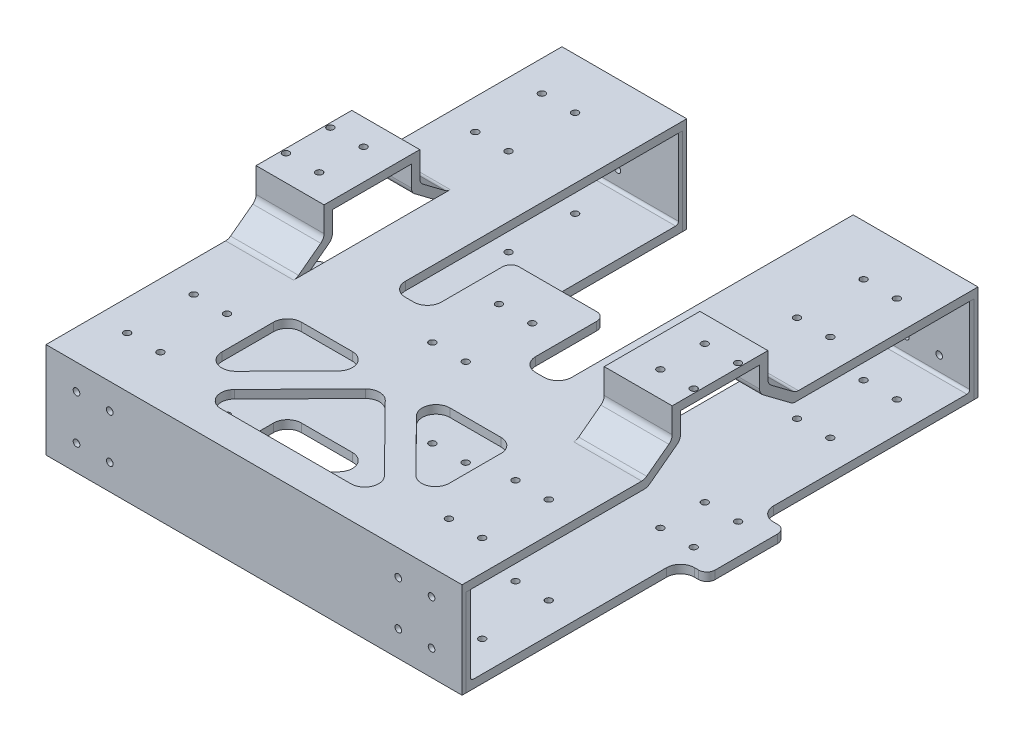
from build123d import *

# Parameters (mm, degrees)
BOSS_EXTRUDE1_DEPTH            = 84.5
BOSS_EXTRUDE2_DEPTH            = 34
BOSS_EXTRUDE4_DEPTH            = 50.5
CUT_EXTRUDE1_DEPTH             = 53.5
SKETCH16_W                     = 9.5
SKETCH16_H                     = 28.5
CUT_EXTRUDE2_DEPTH             = 3
SKETCH13_W                     = 1.2
SKETCH13_H                     = 52.5
M2_CLEARANCE_HOLE4_AT_2_COUNT  = 2
M2_CLEARANCE_HOLE4_AT_2_PITCH  = 12
M2_CLEARANCE_HOLE4_AT_3_COUNT  = 2
M2_CLEARANCE_HOLE4_AT_3_PITCH  = 26.83281573
M2_CLEARANCE_HOLE4_AT_4_COUNT  = 2
M2_CLEARANCE_HOLE4_AT_4_PITCH  = 24
M2_CLEARANCE_HOLE4_AT_5_COUNT  = 2
M2_CLEARANCE_HOLE4_AT_5_PITCH  = 70.127116724
M2_CLEARANCE_HOLE4_AT_6_COUNT  = 2
M2_CLEARANCE_HOLE4_AT_6_PITCH  = 85.497441482
M2_CLEARANCE_HOLE4_AT_7_COUNT  = 2
M2_CLEARANCE_HOLE4_AT_7_PITCH  = 149.980832109
M2_CLEARANCE_HOLE4_AT_8_COUNT  = 2
M2_CLEARANCE_HOLE4_AT_8_PITCH  = 149.5
M2_CLEARANCE_HOLE4_AT_9_COUNT  = 2
M2_CLEARANCE_HOLE4_AT_9_PITCH  = 125.5
M2_CLEARANCE_HOLE4_AT_10_COUNT = 2
M2_CLEARANCE_HOLE4_AT_10_PITCH = 126.072399834
M2_CLEARANCE_HOLE4_AT_11_COUNT = 2
M2_CLEARANCE_HOLE4_AT_11_PITCH = 69.465319451
M2_CLEARANCE_HOLE4_AT_12_COUNT = 2
M2_CLEARANCE_HOLE4_AT_12_PITCH = 88.881582923
M2_CLEARANCE_HOLE4_AT_13_COUNT = 2
M2_CLEARANCE_HOLE4_AT_13_PITCH = 67.422640856
M2_CLEARANCE_HOLE4_AT_14_COUNT = 2
M2_CLEARANCE_HOLE4_AT_14_PITCH = 83.293532162
SKETCH18_W                     = 1.2
SKETCH18_H                     = 186
M2_CLEARANCE_HOLE5_AT_2_COUNT  = 2
M2_CLEARANCE_HOLE5_AT_2_PITCH  = 16
M2_CLEARANCE_HOLE5_AT_3_COUNT  = 2
M2_CLEARANCE_HOLE5_AT_3_PITCH  = 20
M2_CLEARANCE_HOLE5_AT_4_COUNT  = 2
M2_CLEARANCE_HOLE5_AT_4_PITCH  = 12
CUT_EXTRUDE3_DEPTH             = 53.5
FILLET1_R                      = 5
FILLET2_R                      = 3
FILLET3_R                      = 1
FILLET5_R                      = 3
FILLET7_R                      = 5


with BuildPart() as part:
    # Sketch4 → Boss-Extrude1 (new body)
    with BuildSketch(Plane(origin=(0, 0, 0), x_dir=(0, 0, -1), z_dir=(1, 0, 0))):
        Polygon((-91.5, 28.5), (-90, 28.5), (-90, 0), (90, 0), (90, 28.5), (91.5, 28.5), (91.5, -3), (-91.5, -3), align=None)
    extrude(amount=BOSS_EXTRUDE1_DEPTH)


with BuildPart() as body_2:
    # Sketch14 → Boss-Extrude2 (new body)
    with BuildSketch(Plane(origin=(50.499999928, 0, 0), x_dir=(0, 0, -1), z_dir=(1, 0, 0))):
        Polygon((-93, -3), (-91.5, -3), (-91.5, 28.5), (-26.25, 28.5), (-22.25, 31.5), (-27.25, 31.5), (-93, 31.5), align=None)
        Polygon((-27.25, 31.5), (-22.25, 31.5), (-14.25, 37.5), (-14.25, 46.5), (14.25, 46.5), (14.25, 37.5), (22.25, 31.5), (27.25, 31.5), (17.25, 39), (17.25, 49.5), (-17.25, 49.5), (-17.25, 39), align=None)
        Polygon((22.25, 31.5), (26.25, 28.5), (91.5, 28.5), (91.5, -3), (93, -3), (93, 31.5), (27.25, 31.5), align=None)
    extrude(amount=BOSS_EXTRUDE2_DEPTH)

    # Sketch14_6 → Boss-Extrude4 (add)
    with BuildSketch(Plane(origin=(50.499999928, 0, 0), x_dir=(0, 0, -1), z_dir=(1, 0, 0))):
        Polygon((-93, -3), (-91.5, -3), (-91.5, 28.5), (91.5, 28.5), (91.5, -3), (93, -3), (93, 31.5), (-93, 31.5), align=None)
    extrude(amount=-BOSS_EXTRUDE4_DEPTH)


with BuildPart() as cut_extrude1_tool:
    # Sketch7 → Cut-Extrude1 (new body, through all)
    with BuildSketch(Plane.XZ.offset(3)):
        Polygon((84.5, -14.25), (75, -14.25), (75, -93), (84.499999928, -93), align=None)
        Polygon((84.5, 14.25), (75, 14.25), (75, 93), (84.499999928, 93), align=None)
        Polygon((0, -93), (30, -93), (30, 13.447808823), (17, 13.447808823), (17, -16.552191177), (0, -16.552191177), align=None)
    extrude(amount=-CUT_EXTRUDE1_DEPTH)


with BuildPart() as part_1:
    add(part.part)

    # Cut-Extrude1: cut by cut_extrude1_tool
    add(cut_extrude1_tool.part, mode=Mode.SUBTRACT)


with BuildPart() as body_2_1:
    add(body_2.part)

    # Cut-Extrude1: cut by cut_extrude1_tool
    add(cut_extrude1_tool.part, mode=Mode.SUBTRACT)

    # Sketch16 → Cut-Extrude2 (cut)
    with BuildSketch(Plane(origin=(0, 49.5, 0), x_dir=(1, 0, 0), z_dir=(0, 1, 0))):
        with Locations((79.75, 0)):
            Rectangle(SKETCH16_W, SKETCH16_H)
    extrude(amount=-CUT_EXTRUDE2_DEPTH, mode=Mode.SUBTRACT)


with BuildPart() as m2_clearance_hole4_tool:
    # Sketch13 → M2 Clearance Hole4 (revolve)
    with BuildSketch(Plane(origin=(52, -3, 74.75), x_dir=(0, 0, -1), z_dir=(1, 0, 0))):
        with Locations((0.6, 26.25)):
            Rectangle(SKETCH13_W, SKETCH13_H)
    m2_clearance_hole4 = revolve(axis=Axis((52, -9.35, 74.75), (0, 1, 0)))


with BuildPart() as part_2:
    add(part_1.part)

    # M2 Clearance Hole4: cut by m2_clearance_hole4_tool
    add(m2_clearance_hole4_tool.part, mode=Mode.SUBTRACT)


with BuildPart() as body_2_2:
    add(body_2_1.part)

    # M2 Clearance Hole4: cut by m2_clearance_hole4_tool
    add(m2_clearance_hole4_tool.part, mode=Mode.SUBTRACT)


with BuildPart() as m2_clearance_hole4_at_2_tool:
    # M2 Clearance Hole4 at 2: M2 Clearance Hole4 ×2
    with Locations(*[(i * M2_CLEARANCE_HOLE4_AT_2_PITCH, 0, 0) for i in range(1, M2_CLEARANCE_HOLE4_AT_2_COUNT)]):
        add(m2_clearance_hole4)


with BuildPart() as part_3:
    add(part_2.part)

    # M2 Clearance Hole4 at 2: cut by m2_clearance_hole4_at_2_tool
    add(m2_clearance_hole4_at_2_tool.part, mode=Mode.SUBTRACT)


with BuildPart() as body_2_3:
    add(body_2_2.part)

    # M2 Clearance Hole4 at 2: cut by m2_clearance_hole4_at_2_tool
    add(m2_clearance_hole4_at_2_tool.part, mode=Mode.SUBTRACT)


with BuildPart() as m2_clearance_hole4_at_3_tool:
    # M2 Clearance Hole4 at 3: M2 Clearance Hole4 ×2
    with Locations(*[Vector(0.447213595, 0, -0.894427191) * (i * M2_CLEARANCE_HOLE4_AT_3_PITCH) for i in range(1, M2_CLEARANCE_HOLE4_AT_3_COUNT)]):
        add(m2_clearance_hole4)


with BuildPart() as part_4:
    add(part_3.part)

    # M2 Clearance Hole4 at 3: cut by m2_clearance_hole4_at_3_tool
    add(m2_clearance_hole4_at_3_tool.part, mode=Mode.SUBTRACT)


with BuildPart() as body_2_4:
    add(body_2_3.part)

    # M2 Clearance Hole4 at 3: cut by m2_clearance_hole4_at_3_tool
    add(m2_clearance_hole4_at_3_tool.part, mode=Mode.SUBTRACT)


with BuildPart() as m2_clearance_hole4_at_4_tool:
    # M2 Clearance Hole4 at 4: M2 Clearance Hole4 ×2
    with Locations(*[(0, 0, -i * M2_CLEARANCE_HOLE4_AT_4_PITCH) for i in range(1, M2_CLEARANCE_HOLE4_AT_4_COUNT)]):
        add(m2_clearance_hole4)


with BuildPart() as part_5:
    add(part_4.part)

    # M2 Clearance Hole4 at 4: cut by m2_clearance_hole4_at_4_tool
    add(m2_clearance_hole4_at_4_tool.part, mode=Mode.SUBTRACT)


with BuildPart() as body_2_5:
    add(body_2_4.part)

    # M2 Clearance Hole4 at 4: cut by m2_clearance_hole4_at_4_tool
    add(m2_clearance_hole4_at_4_tool.part, mode=Mode.SUBTRACT)


with BuildPart() as m2_clearance_hole4_at_5_tool:
    # M2 Clearance Hole4 at 5: M2 Clearance Hole4 ×2
    with Locations(*[Vector(0.306586111, 0, -0.951842926) * (i * M2_CLEARANCE_HOLE4_AT_5_PITCH) for i in range(1, M2_CLEARANCE_HOLE4_AT_5_COUNT)]):
        add(m2_clearance_hole4)


with BuildPart() as part_6:
    add(part_5.part)

    # M2 Clearance Hole4 at 5: cut by m2_clearance_hole4_at_5_tool
    add(m2_clearance_hole4_at_5_tool.part, mode=Mode.SUBTRACT)


with BuildPart() as body_2_6:
    add(body_2_5.part)

    # M2 Clearance Hole4 at 5: cut by m2_clearance_hole4_at_5_tool
    add(m2_clearance_hole4_at_5_tool.part, mode=Mode.SUBTRACT)


with BuildPart() as m2_clearance_hole4_at_6_tool:
    # M2 Clearance Hole4 at 6: M2 Clearance Hole4 ×2
    with Locations(*[Vector(0.251469513, 0, -0.96786522) * (i * M2_CLEARANCE_HOLE4_AT_6_PITCH) for i in range(1, M2_CLEARANCE_HOLE4_AT_6_COUNT)]):
        add(m2_clearance_hole4)


with BuildPart() as part_7:
    add(part_6.part)

    # M2 Clearance Hole4 at 6: cut by m2_clearance_hole4_at_6_tool
    add(m2_clearance_hole4_at_6_tool.part, mode=Mode.SUBTRACT)


with BuildPart() as body_2_7:
    add(body_2_6.part)

    # M2 Clearance Hole4 at 6: cut by m2_clearance_hole4_at_6_tool
    add(m2_clearance_hole4_at_6_tool.part, mode=Mode.SUBTRACT)


with BuildPart() as m2_clearance_hole4_at_7_tool:
    # M2 Clearance Hole4 at 7: M2 Clearance Hole4 ×2
    with Locations(*[Vector(0.080010224, 0, -0.996794043) * (i * M2_CLEARANCE_HOLE4_AT_7_PITCH) for i in range(1, M2_CLEARANCE_HOLE4_AT_7_COUNT)]):
        add(m2_clearance_hole4)


with BuildPart() as part_8:
    add(part_7.part)

    # M2 Clearance Hole4 at 7: cut by m2_clearance_hole4_at_7_tool
    add(m2_clearance_hole4_at_7_tool.part, mode=Mode.SUBTRACT)


with BuildPart() as body_2_8:
    add(body_2_7.part)

    # M2 Clearance Hole4 at 7: cut by m2_clearance_hole4_at_7_tool
    add(m2_clearance_hole4_at_7_tool.part, mode=Mode.SUBTRACT)


with BuildPart() as m2_clearance_hole4_at_8_tool:
    # M2 Clearance Hole4 at 8: M2 Clearance Hole4 ×2
    with Locations(*[(0, 0, -i * M2_CLEARANCE_HOLE4_AT_8_PITCH) for i in range(1, M2_CLEARANCE_HOLE4_AT_8_COUNT)]):
        add(m2_clearance_hole4)


with BuildPart() as part_9:
    add(part_8.part)

    # M2 Clearance Hole4 at 8: cut by m2_clearance_hole4_at_8_tool
    add(m2_clearance_hole4_at_8_tool.part, mode=Mode.SUBTRACT)


with BuildPart() as body_2_9:
    add(body_2_8.part)

    # M2 Clearance Hole4 at 8: cut by m2_clearance_hole4_at_8_tool
    add(m2_clearance_hole4_at_8_tool.part, mode=Mode.SUBTRACT)


with BuildPart() as m2_clearance_hole4_at_9_tool:
    # M2 Clearance Hole4 at 9: M2 Clearance Hole4 ×2
    with Locations(*[(0, 0, -i * M2_CLEARANCE_HOLE4_AT_9_PITCH) for i in range(1, M2_CLEARANCE_HOLE4_AT_9_COUNT)]):
        add(m2_clearance_hole4)


with BuildPart() as part_10:
    add(part_9.part)

    # M2 Clearance Hole4 at 9: cut by m2_clearance_hole4_at_9_tool
    add(m2_clearance_hole4_at_9_tool.part, mode=Mode.SUBTRACT)


with BuildPart() as body_2_10:
    add(body_2_9.part)

    # M2 Clearance Hole4 at 9: cut by m2_clearance_hole4_at_9_tool
    add(m2_clearance_hole4_at_9_tool.part, mode=Mode.SUBTRACT)


with BuildPart() as m2_clearance_hole4_at_10_tool:
    # M2 Clearance Hole4 at 10: M2 Clearance Hole4 ×2
    with Locations(*[Vector(0.095183403, 0, -0.995459753) * (i * M2_CLEARANCE_HOLE4_AT_10_PITCH) for i in range(1, M2_CLEARANCE_HOLE4_AT_10_COUNT)]):
        add(m2_clearance_hole4)


with BuildPart() as part_11:
    add(part_10.part)

    # M2 Clearance Hole4 at 10: cut by m2_clearance_hole4_at_10_tool
    add(m2_clearance_hole4_at_10_tool.part, mode=Mode.SUBTRACT)


with BuildPart() as body_2_11:
    add(body_2_10.part)

    # M2 Clearance Hole4 at 10: cut by m2_clearance_hole4_at_10_tool
    add(m2_clearance_hole4_at_10_tool.part, mode=Mode.SUBTRACT)


with BuildPart() as m2_clearance_hole4_at_11_tool:
    # M2 Clearance Hole4 at 11: M2 Clearance Hole4 ×2
    with Locations(*[Vector(-0.662200942, 0, -0.749326305) * (i * M2_CLEARANCE_HOLE4_AT_11_PITCH) for i in range(1, M2_CLEARANCE_HOLE4_AT_11_COUNT)]):
        add(m2_clearance_hole4)


with BuildPart() as part_12:
    add(part_11.part)

    # M2 Clearance Hole4 at 11: cut by m2_clearance_hole4_at_11_tool
    add(m2_clearance_hole4_at_11_tool.part, mode=Mode.SUBTRACT)


with BuildPart() as body_2_12:
    add(body_2_11.part)

    # M2 Clearance Hole4 at 11: cut by m2_clearance_hole4_at_11_tool
    add(m2_clearance_hole4_at_11_tool.part, mode=Mode.SUBTRACT)


with BuildPart() as m2_clearance_hole4_at_12_tool:
    # M2 Clearance Hole4 at 12: M2 Clearance Hole4 ×2
    with Locations(*[Vector(-0.517542538, 0, -0.855657479) * (i * M2_CLEARANCE_HOLE4_AT_12_PITCH) for i in range(1, M2_CLEARANCE_HOLE4_AT_12_COUNT)]):
        add(m2_clearance_hole4)


with BuildPart() as part_13:
    add(part_12.part)

    # M2 Clearance Hole4 at 12: cut by m2_clearance_hole4_at_12_tool
    add(m2_clearance_hole4_at_12_tool.part, mode=Mode.SUBTRACT)


with BuildPart() as body_2_13:
    add(body_2_12.part)

    # M2 Clearance Hole4 at 12: cut by m2_clearance_hole4_at_12_tool
    add(m2_clearance_hole4_at_12_tool.part, mode=Mode.SUBTRACT)


with BuildPart() as m2_clearance_hole4_at_13_tool:
    # M2 Clearance Hole4 at 13: M2 Clearance Hole4 ×2
    with Locations(*[Vector(0.140902223, 0, -0.990023517) * (i * M2_CLEARANCE_HOLE4_AT_13_PITCH) for i in range(1, M2_CLEARANCE_HOLE4_AT_13_COUNT)]):
        add(m2_clearance_hole4)


with BuildPart() as part_14:
    add(part_13.part)

    # M2 Clearance Hole4 at 13: cut by m2_clearance_hole4_at_13_tool
    add(m2_clearance_hole4_at_13_tool.part, mode=Mode.SUBTRACT)


with BuildPart() as body_2_14:
    add(body_2_13.part)

    # M2 Clearance Hole4 at 13: cut by m2_clearance_hole4_at_13_tool
    add(m2_clearance_hole4_at_13_tool.part, mode=Mode.SUBTRACT)


with BuildPart() as m2_clearance_hole4_at_14_tool:
    # M2 Clearance Hole4 at 14: M2 Clearance Hole4 ×2
    with Locations(*[Vector(0.114054474, 0, -0.993474497) * (i * M2_CLEARANCE_HOLE4_AT_14_PITCH) for i in range(1, M2_CLEARANCE_HOLE4_AT_14_COUNT)]):
        add(m2_clearance_hole4)


with BuildPart() as part_15:
    add(part_14.part)

    # M2 Clearance Hole4 at 14: cut by m2_clearance_hole4_at_14_tool
    add(m2_clearance_hole4_at_14_tool.part, mode=Mode.SUBTRACT)


with BuildPart() as body_2_15:
    add(body_2_14.part)

    # M2 Clearance Hole4 at 14: cut by m2_clearance_hole4_at_14_tool
    add(m2_clearance_hole4_at_14_tool.part, mode=Mode.SUBTRACT)


with BuildPart() as m2_clearance_hole5_tool:
    # Sketch18 → M2 Clearance Hole5 (revolve)
    with BuildSketch(Plane(origin=(52, 22.25, 93), x_dir=(0, -1, 0), z_dir=(1, 0, 0))):
        with Locations((0.6, 93)):
            Rectangle(SKETCH18_W, SKETCH18_H)
    m2_clearance_hole5 = revolve(axis=Axis((52, 22.25, 99.35), (0, 0, -1)))


with BuildPart() as part_16:
    add(part_15.part)

    # M2 Clearance Hole5: cut by m2_clearance_hole5_tool
    add(m2_clearance_hole5_tool.part, mode=Mode.SUBTRACT)


with BuildPart() as body_2_16:
    add(body_2_15.part)

    # M2 Clearance Hole5: cut by m2_clearance_hole5_tool
    add(m2_clearance_hole5_tool.part, mode=Mode.SUBTRACT)


with BuildPart() as m2_clearance_hole5_at_2_tool:
    # M2 Clearance Hole5 at 2: M2 Clearance Hole5 ×2
    with Locations(*[(0, -i * M2_CLEARANCE_HOLE5_AT_2_PITCH, 0) for i in range(1, M2_CLEARANCE_HOLE5_AT_2_COUNT)]):
        add(m2_clearance_hole5)


with BuildPart() as part_17:
    add(part_16.part)

    # M2 Clearance Hole5 at 2: cut by m2_clearance_hole5_at_2_tool
    add(m2_clearance_hole5_at_2_tool.part, mode=Mode.SUBTRACT)


with BuildPart() as body_2_17:
    add(body_2_16.part)

    # M2 Clearance Hole5 at 2: cut by m2_clearance_hole5_at_2_tool
    add(m2_clearance_hole5_at_2_tool.part, mode=Mode.SUBTRACT)


with BuildPart() as m2_clearance_hole5_at_3_tool:
    # M2 Clearance Hole5 at 3: M2 Clearance Hole5 ×2
    with Locations(*[Vector(0.6, -0.8, 0) * (i * M2_CLEARANCE_HOLE5_AT_3_PITCH) for i in range(1, M2_CLEARANCE_HOLE5_AT_3_COUNT)]):
        add(m2_clearance_hole5)


with BuildPart() as part_18:
    add(part_17.part)

    # M2 Clearance Hole5 at 3: cut by m2_clearance_hole5_at_3_tool
    add(m2_clearance_hole5_at_3_tool.part, mode=Mode.SUBTRACT)


with BuildPart() as body_2_18:
    add(body_2_17.part)

    # M2 Clearance Hole5 at 3: cut by m2_clearance_hole5_at_3_tool
    add(m2_clearance_hole5_at_3_tool.part, mode=Mode.SUBTRACT)


with BuildPart() as m2_clearance_hole5_at_4_tool:
    # M2 Clearance Hole5 at 4: M2 Clearance Hole5 ×2
    with Locations(*[(i * M2_CLEARANCE_HOLE5_AT_4_PITCH, 0, 0) for i in range(1, M2_CLEARANCE_HOLE5_AT_4_COUNT)]):
        add(m2_clearance_hole5)


with BuildPart() as part_19:
    add(part_18.part)

    # M2 Clearance Hole5 at 4: cut by m2_clearance_hole5_at_4_tool
    add(m2_clearance_hole5_at_4_tool.part, mode=Mode.SUBTRACT)

    # Mirror1: part across plane


with BuildPart() as body_2_19:
    add(body_2_18.part)

    # M2 Clearance Hole5 at 4: cut by m2_clearance_hole5_at_4_tool
    add(m2_clearance_hole5_at_4_tool.part, mode=Mode.SUBTRACT)

    # Mirror1 2: body 2 across plane


with BuildPart() as part_20:
    add(part_19.part)
    add(part_19.part.mirror(Plane(origin=(0, 0, 0), x_dir=(0, 0, 1), z_dir=(1, 0, 0))))


with BuildPart() as body_2_20:
    add(body_2_19.part)
    add(body_2_19.part.mirror(Plane(origin=(0, 0, 0), x_dir=(0, 0, 1), z_dir=(1, 0, 0))))


with BuildPart() as cut_extrude3_tool:
    # Sketch19 → Cut-Extrude3 (new body, through all)
    with BuildSketch(Plane.XZ.offset(3)):
        Polygon((41, 75.804924873), (5.619392711, 39.947808823), (41, 39.947808823), align=None)
        Polygon((35.380607289, 81.5), (-35.380607289, 81.5), (0, 45.64288395), align=None)
        Polygon((-5.619392711, 39.947808823), (-41, 75.804924873), (-41, 39.947808823), align=None)
    extrude(amount=-CUT_EXTRUDE3_DEPTH)


with BuildPart() as part_21:
    add(part_20.part)

    # Cut-Extrude3: cut by cut_extrude3_tool
    add(cut_extrude3_tool.part, mode=Mode.SUBTRACT)

    # Fillet1
    fillet1_edges = [part_21.edges().sort_by_distance(p)[0] for p in [
        (-17, -1.5, 13.447808823),
        (-30, -1.5, 13.447808823),
        (-75, -1.5, 14.25),
        (-75, -1.5, -14.25),
        (41, -1.5, 75.804924873),
        (41, -1.5, 39.947808823),
        (5.619392711, -1.5, 39.947808823),
        (0, -1.5, 45.64288395),
        (-35.380607289, -1.5, 81.5),
        (35.380607289, -1.5, 81.5),
        (-5.619392711, -1.5, 39.947808823),
        (-41, -1.5, 39.947808823),
        (-41, -1.5, 75.804924873),
        (75, -1.5, -14.25),
        (75, -1.5, 14.25),
        (17, -1.5, 13.447808823),
        (30, -1.5, 13.447808823),
    ]]
    fillet(fillet1_edges, radius=FILLET1_R)

    # Fillet2
    fillet2_edges = [part_21.edges().sort_by_distance(p)[0] for p in [
        (-84.5, -1.5, -14.25),
        (84.5, -1.5, 14.25),
        (-84.5, -1.5, 14.25),
        (-17, -1.5, -16.552191177),
        (84.5, -1.5, -14.25),
    ]]
    fillet(fillet2_edges, radius=FILLET2_R)

    # Fillet3
    fillet3_edges = [part_21.edges().sort_by_distance(p)[0] for p in [
        (-52.5, 0, -90),
        (0, 0, 90),
        (52.5, 0, -90),
    ]]
    fillet(fillet3_edges, radius=FILLET3_R)


with BuildPart() as body_2_21:
    add(body_2_20.part)

    # Cut-Extrude3: cut by cut_extrude3_tool
    add(cut_extrude3_tool.part, mode=Mode.SUBTRACT)

    # Fillet5
    fillet5_edges = [body_2_21.edges().sort_by_distance(p)[0] for p in [
        (62.749999964, 28.5, -26.25),
        (62.749999964, 28.5, 26.25),
        (62.749999964, 31.5, 27.25),
        (62.749999964, 31.5, -27.25),
        (62.749999964, 39, 17.25),
        (62.749999964, 39, -17.25),
        (62.749999964, 37.5, -14.25),
        (62.749999964, 37.5, 14.25),
        (17, 30, -16.552191177),
        (-62.749999964, 37.5, 14.25),
        (-62.749999964, 37.5, -14.25),
        (-62.749999964, 28.5, -26.25),
        (-62.749999964, 39, -17.25),
        (-62.749999964, 39, 17.25),
        (-62.749999964, 31.5, 27.25),
        (-62.749999964, 31.5, -27.25),
        (-62.749999964, 28.5, 26.25),
        (-17, 30, -16.552191177),
    ]]
    fillet(fillet5_edges, radius=FILLET5_R)

    # Fillet7
    fillet7_edges = [body_2_21.edges().sort_by_distance(p)[0] for p in [
        (17, 30, 13.447808823),
        (30, 30, 13.447808823),
        (-17, 30, 13.447808823),
        (-30, 30, 13.447808823),
        (41, 30, 75.804924873),
        (41, 30, 39.947808823),
        (5.619392711, 30, 39.947808823),
        (0, 30, 45.64288395),
        (-35.380607289, 30, 81.5),
        (35.380607289, 30, 81.5),
        (-5.619392711, 30, 39.947808823),
        (-41, 30, 39.947808823),
        (-41, 30, 75.804924873),
    ]]
    fillet(fillet7_edges, radius=FILLET7_R)


solid = Compound([part_21.part, body_2_21.part])
